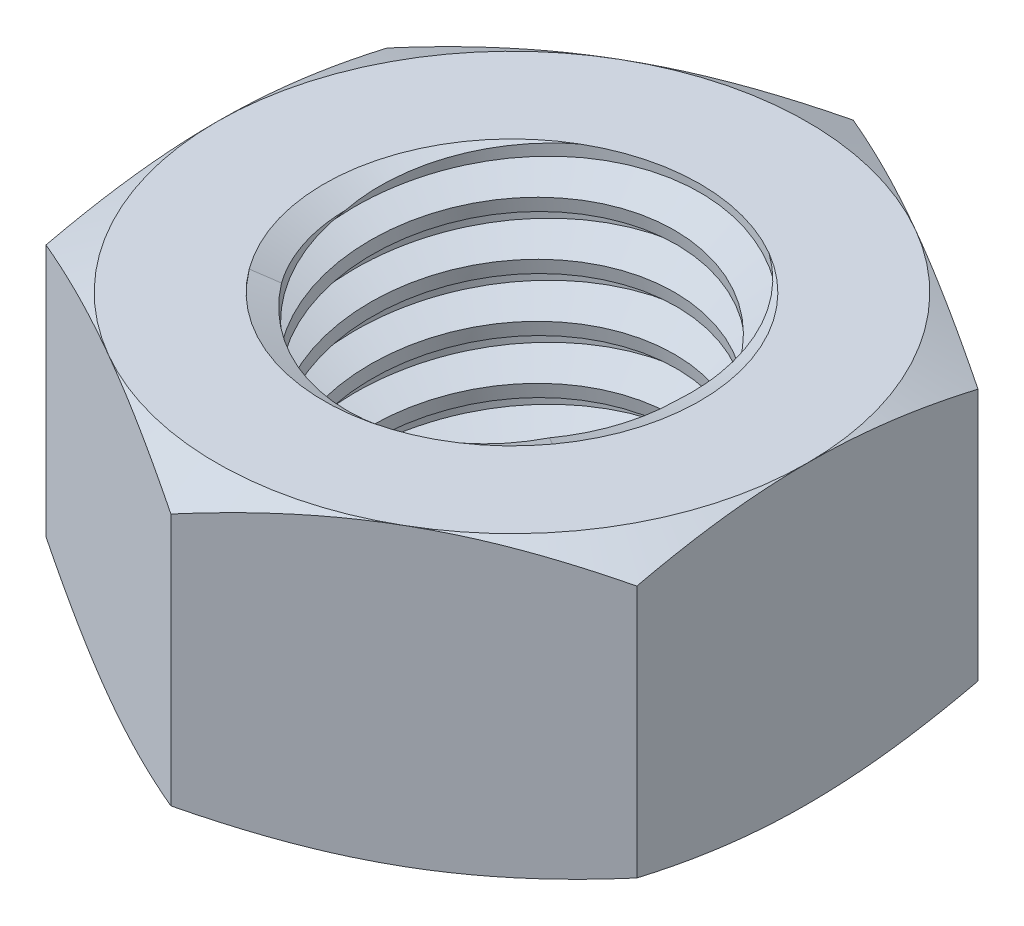
from build123d import *

# Parameters (mm, degrees)
EXTRUDE1_DEPTH       = 5.5
SKETCH2_W            = 7
SKETCH2_H            = 11
LPATTERN1_COUNT      = 6
LPATTERN1_PITCH      = 2
LPATTERN1_COUNT_DIR2 = 2
LPATTERN1_PITCH_DIR2 = 2


with BuildPart() as part:
    # Sketch1 → Extrude1 (new, symmetric)
    with BuildSketch(Plane(origin=(0, 0, 0), x_dir=(1, 0, 0), z_dir=(0, 1, 0))):
        Polygon((0, 12.701705922), (-11, 6.350852961), (-11, -6.350852961), (0, -12.701705922), (11, -6.350852961), (11, 6.350852961), align=None)
    extrude(amount=EXTRUDE1_DEPTH, both=True)

    # Sketch4 → Cut-Revolve2 (revolve, cut)
    with BuildSketch(Plane(origin=(0, 0, 0), x_dir=(0, 0, -1), z_dir=(1, 0, 0))):
        Polygon((0, 5.5), (7, 5.5), (6.052091924, 5.057983205), (6.052091924, -5.057983205), (7, -5.5), (0, -5.5), align=None)
    revolve(axis=Axis((0, 5.5, 0), (0, 1, 0)), mode=Mode.SUBTRACT)


with BuildPart() as body_2:
    # Sketch2 → Revolve1 (revolve)
    with BuildSketch(Plane(origin=(0, 0, 0), x_dir=(0, 0, -1), z_dir=(1, 0, 0))):
        with Locations((3.5, 0)):
            Rectangle(SKETCH2_W, SKETCH2_H)
    revolve(axis=Axis((0, -12.5, 0), (0, 1, 0)))

    # Sketch3 → Cut-Revolve1 (revolve, cut)
    with BuildSketch(Plane(origin=(0, 0, 0), x_dir=(0, 0, -1), z_dir=(1, 0, 0))):
        Polygon((7.035355339, 5.252512627), (7.282842712, 3.520101013), (6.122802602, 3.985726337), (6.052091924, 4.480701084), align=None)
    cut_revolve1 = revolve(axis=Axis((0, 5.5, 0.305203088), (0, -0.9899494936611666, -0.14142135623730978)), mode=Mode.SUBTRACT)

    # LPattern1: Cut-Revolve1 6 × 2
    with Locations(*[Vector(0, -1, 0) * (i * LPATTERN1_PITCH) + Vector(0, 1, 0) * (j * LPATTERN1_PITCH_DIR2) for i in range(LPATTERN1_COUNT) for j in range(LPATTERN1_COUNT_DIR2) if (i, j) != (0, 0)]):
        add(cut_revolve1, mode=Mode.SUBTRACT)


with BuildPart() as part_1:
    add(part.part)

    # Combine1: cut body 2
    add(body_2.part, mode=Mode.SUBTRACT)

    # Sketch5 → Cut-Revolve3 (revolve, cut)
    with BuildSketch(Plane(origin=(0, 0, 0), x_dir=(0, 0, -1), z_dir=(1, 0, 0))):
        Polygon((0, -5.5), (11, -5.5), (12.701705922, -4.706481497), (12.701705922, 4.706481497), (11, 5.5), (0, 5.5), (0, 6.77), (13.971705922, 6.77), (13.971705922, -6.77), (0, -6.77), align=None)
    revolve(axis=Axis((0, -5.5, 0), (0, 1, 0)), mode=Mode.SUBTRACT)


solid = part_1.part
